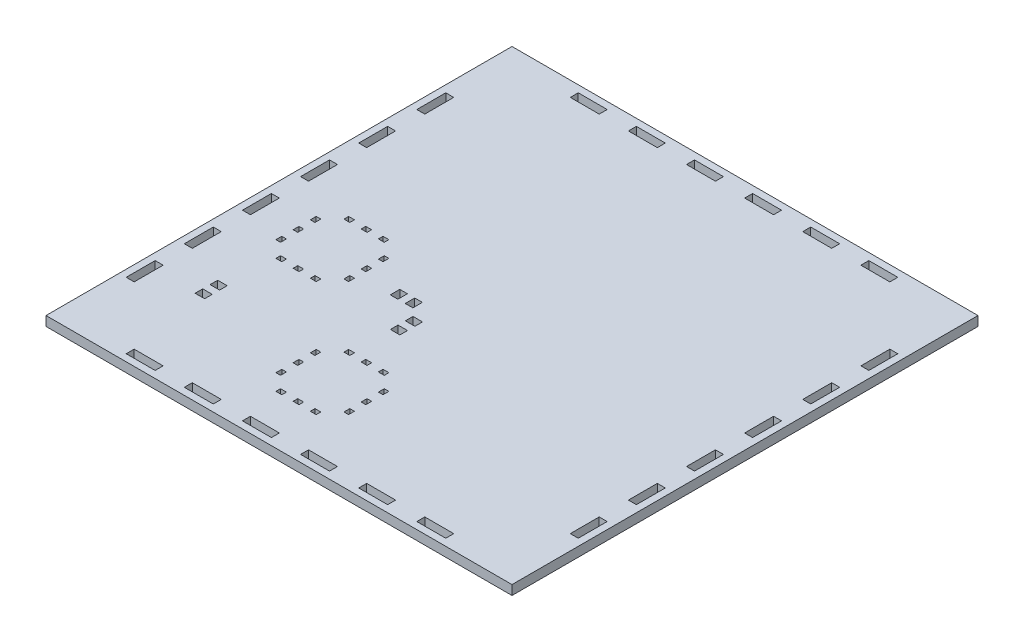
from build123d import *

# Parameters (mm, degrees)
SKETCH1_W           = 311.4
SKETCH1_H           = 311.4
SKETCH1_W_2         = 5.4
SKETCH1_H_2         = 19.425
SKETCH1_W_3         = 19.425
SKETCH1_H_3         = 5.4
SKETCH1_W_4         = 4.000000243
SKETCH1_H_4         = 3.174999693
SKETCH1_W_5         = 3.175000307
SKETCH1_H_5         = 3.999999757
SKETCH1_H_6         = 3.999999756
SKETCH1_W_6         = 4
SKETCH1_H_7         = 3.175
SKETCH1_W_7         = 3.175
SKETCH1_H_8         = 4
SKETCH1_W_8         = 3.174999693
SKETCH1_H_9         = 4.000000243
SKETCH1_H_10        = 4.000000244
BOSS_EXTRUDE4_DEPTH = 6.35
SKETCH4_W           = 19.425
SKETCH4_H           = 5.4
SKETCH4_W_2         = 5.4
SKETCH4_H_2         = 19.425
CUT_EXTRUDE3_DEPTH  = 6.35
SKETCH5_W           = 311.48128
SKETCH5_H           = 311.48128
SKETCH5_W_2         = 19.34372
SKETCH5_H_2         = 5.31872
SKETCH5_W_3         = 5.31872
SKETCH5_H_3         = 19.34372
SKETCH5_W_4         = 3.918720243
SKETCH5_H_4         = 3.093719693
SKETCH5_W_5         = 3.09372
SKETCH5_H_5         = 3.91872
SKETCH5_W_6         = 3.91872
SKETCH5_H_6         = 3.09372
SKETCH5_W_7         = 3.093720307
SKETCH5_H_7         = 3.918719757
SKETCH5_H_8         = 3.918719756
SKETCH5_W_8         = 3.093719693
SKETCH5_H_9         = 3.918720243
SKETCH5_H_10        = 3.918720244
BOSS_EXTRUDE5_DEPTH = 6.35
SKETCH7_W           = 6.35
SKETCH7_H           = 5.081279906
SKETCH7_W_2         = 5.081279906
SKETCH7_H_2         = 6.35
CUT_EXTRUDE4_DEPTH  = 6.35


with BuildPart() as part:
    # Sketch1 → Boss-Extrude4 (new body)
    with BuildSketch(Plane(origin=(0, 0, 0), x_dir=(1, 0, 0), z_dir=(0, 1, 0))):
        with Locations((148.1875, 148.2125)):
            Rectangle(SKETCH1_W, SKETCH1_H)
        with Locations((-0.2125, 51.075)):
            Rectangle(SKETCH1_W_2, SKETCH1_H_2, mode=Mode.SUBTRACT)
        with Locations((-0.2125, 89.925)):
            Rectangle(SKETCH1_W_2, SKETCH1_H_2, mode=Mode.SUBTRACT)
        with Locations((-0.2125, 128.775)):
            Rectangle(SKETCH1_W_2, SKETCH1_H_2, mode=Mode.SUBTRACT)
        with Locations((-0.2125, 167.625)):
            Rectangle(SKETCH1_W_2, SKETCH1_H_2, mode=Mode.SUBTRACT)
        with Locations((-0.2125, 206.475)):
            Rectangle(SKETCH1_W_2, SKETCH1_H_2, mode=Mode.SUBTRACT)
        with Locations((-0.2125, 245.325)):
            Rectangle(SKETCH1_W_2, SKETCH1_H_2, mode=Mode.SUBTRACT)
        with Locations((51.075, 296.6125)):
            Rectangle(SKETCH1_W_3, SKETCH1_H_3, mode=Mode.SUBTRACT)
        with Locations((89.925, 296.6125)):
            Rectangle(SKETCH1_W_3, SKETCH1_H_3, mode=Mode.SUBTRACT)
        with Locations((128.775, 296.6125)):
            Rectangle(SKETCH1_W_3, SKETCH1_H_3, mode=Mode.SUBTRACT)
        with Locations((167.625, 296.6125)):
            Rectangle(SKETCH1_W_3, SKETCH1_H_3, mode=Mode.SUBTRACT)
        with Locations((206.475, 296.6125)):
            Rectangle(SKETCH1_W_3, SKETCH1_H_3, mode=Mode.SUBTRACT)
        with Locations((245.325, 296.6125)):
            Rectangle(SKETCH1_W_3, SKETCH1_H_3, mode=Mode.SUBTRACT)
        with Locations((296.5875, 245.35)):
            Rectangle(SKETCH1_W_2, SKETCH1_H_2, mode=Mode.SUBTRACT)
        with Locations((296.5875, 206.5)):
            Rectangle(SKETCH1_W_2, SKETCH1_H_2, mode=Mode.SUBTRACT)
        with Locations((296.5875, 167.65)):
            Rectangle(SKETCH1_W_2, SKETCH1_H_2, mode=Mode.SUBTRACT)
        with Locations((296.5875, 128.8)):
            Rectangle(SKETCH1_W_2, SKETCH1_H_2, mode=Mode.SUBTRACT)
        with Locations((296.5875, 89.95)):
            Rectangle(SKETCH1_W_2, SKETCH1_H_2, mode=Mode.SUBTRACT)
        with Locations((296.5875, 51.1)):
            Rectangle(SKETCH1_W_2, SKETCH1_H_2, mode=Mode.SUBTRACT)
        with Locations((245.3, -0.1875)):
            Rectangle(SKETCH1_W_3, SKETCH1_H_3, mode=Mode.SUBTRACT)
        with Locations((206.45, -0.1875)):
            Rectangle(SKETCH1_W_3, SKETCH1_H_3, mode=Mode.SUBTRACT)
        with Locations((167.6, -0.1875)):
            Rectangle(SKETCH1_W_3, SKETCH1_H_3, mode=Mode.SUBTRACT)
        with Locations((128.75, -0.1875)):
            Rectangle(SKETCH1_W_3, SKETCH1_H_3, mode=Mode.SUBTRACT)
        with Locations((89.9, -0.1875)):
            Rectangle(SKETCH1_W_3, SKETCH1_H_3, mode=Mode.SUBTRACT)
        with Locations((51.05, -0.1875)):
            Rectangle(SKETCH1_W_3, SKETCH1_H_3, mode=Mode.SUBTRACT)
        with Locations((38.162499879, 149.42500074)):
            Rectangle(SKETCH1_W_4, SKETCH1_H_4, mode=Mode.SUBTRACT)
        with Locations((49.662499879, 149.42500074)):
            Rectangle(SKETCH1_W_4, SKETCH1_H_4, mode=Mode.SUBTRACT)
        with Locations((61.162499879, 149.42500074)):
            Rectangle(SKETCH1_W_4, SKETCH1_H_4, mode=Mode.SUBTRACT)
        with Locations((72.40000236, 138.187501742)):
            Rectangle(SKETCH1_W_5, SKETCH1_H_5, mode=Mode.SUBTRACT)
        with Locations((72.40000236, 126.68750181)):
            Rectangle(SKETCH1_W_5, SKETCH1_H_5, mode=Mode.SUBTRACT)
        with Locations((72.40000236, 115.187501877)):
            Rectangle(SKETCH1_W_5, SKETCH1_H_6, mode=Mode.SUBTRACT)
        with Locations((61.162501621, 103.95)):
            Rectangle(SKETCH1_W_6, SKETCH1_H_7, mode=Mode.SUBTRACT)
        with Locations((49.662501621, 103.95)):
            Rectangle(SKETCH1_W_6, SKETCH1_H_7, mode=Mode.SUBTRACT)
        with Locations((38.162501621, 103.95)):
            Rectangle(SKETCH1_W_6, SKETCH1_H_7, mode=Mode.SUBTRACT)
        with Locations((26.925001621, 115.1875)):
            Rectangle(SKETCH1_W_7, SKETCH1_H_8, mode=Mode.SUBTRACT)
        with Locations((26.925001621, 126.6875)):
            Rectangle(SKETCH1_W_7, SKETCH1_H_8, mode=Mode.SUBTRACT)
        with Locations((26.925001621, 138.1875)):
            Rectangle(SKETCH1_W_7, SKETCH1_H_8, mode=Mode.SUBTRACT)
        with Locations((115.162499879, 72.42500074)):
            Rectangle(SKETCH1_W_4, SKETCH1_H_4, mode=Mode.SUBTRACT)
        with Locations((126.662499879, 72.42500074)):
            Rectangle(SKETCH1_W_4, SKETCH1_H_4, mode=Mode.SUBTRACT)
        with Locations((138.162499879, 72.42500074)):
            Rectangle(SKETCH1_W_4, SKETCH1_H_4, mode=Mode.SUBTRACT)
        with Locations((149.400002361, 61.187501743)):
            Rectangle(SKETCH1_W_8, SKETCH1_H_9, mode=Mode.SUBTRACT)
        with Locations((149.400002361, 49.68750181)):
            Rectangle(SKETCH1_W_8, SKETCH1_H_9, mode=Mode.SUBTRACT)
        with Locations((149.400002361, 38.187501877)):
            Rectangle(SKETCH1_W_8, SKETCH1_H_10, mode=Mode.SUBTRACT)
        with Locations((138.162501621, 26.95)):
            Rectangle(SKETCH1_W_6, SKETCH1_H_7, mode=Mode.SUBTRACT)
        with Locations((126.662501621, 26.95)):
            Rectangle(SKETCH1_W_6, SKETCH1_H_7, mode=Mode.SUBTRACT)
        with Locations((115.162501621, 26.95)):
            Rectangle(SKETCH1_W_6, SKETCH1_H_7, mode=Mode.SUBTRACT)
        with Locations((103.925001621, 38.1875)):
            Rectangle(SKETCH1_W_7, SKETCH1_H_8, mode=Mode.SUBTRACT)
        with Locations((103.925001621, 49.6875)):
            Rectangle(SKETCH1_W_7, SKETCH1_H_8, mode=Mode.SUBTRACT)
        with Locations((103.925001621, 61.1875)):
            Rectangle(SKETCH1_W_7, SKETCH1_H_8, mode=Mode.SUBTRACT)
    extrude(amount=BOSS_EXTRUDE4_DEPTH)

    # Sketch4 → Cut-Extrude3 (cut)
    with BuildSketch(Plane(origin=(0, 6.35, 0), x_dir=(1, 0, 0), z_dir=(0, 1, 0))):
        with Locations((12.225, 296.6125)):
            Rectangle(SKETCH4_W, SKETCH4_H)
        with Locations((-0.2125, 284.175)):
            Rectangle(SKETCH4_W_2, SKETCH4_H_2)
        with BuildLine():
            ThreePointArc((2.512500017, 299.287442129), (-1.322027524, 297.714705253), (-2.9125, 293.8875))
            Line((-2.9125, 293.8875), (2.4875, 293.8875))
            Line((2.4875, 293.8875), (2.5125, 293.9125))
            Line((2.5125, 293.9125), (2.5125, 299.287442129))
        make_face()
        with BuildLine():
            Line((293.8875, 293.9125), (299.2875, 293.9125))
            ThreePointArc((299.2875, 293.9125), (297.705876618, 297.730876618), (293.8875, 299.3125))
            Line((293.8875, 299.3125), (293.8875, 293.9125))
        make_face()
        with Locations((284.175, 296.6125)):
            Rectangle(SKETCH4_W, SKETCH4_H)
        with Locations((296.5875, 284.2)):
            Rectangle(SKETCH4_W_2, SKETCH4_H_2)
        with Locations((-0.2125, 12.225)):
            Rectangle(SKETCH4_W_2, SKETCH4_H_2)
        with Locations((12.2, -0.1875)):
            Rectangle(SKETCH4_W, SKETCH4_H)
        with BuildLine():
            ThreePointArc((2.4875, -2.8875), (-1.330876618, -1.305876618), (-2.9125, 2.5125))
            Line((-2.9125, 2.5125), (2.4875, 2.5125))
            Line((2.4875, 2.5125), (2.4875, -2.8875))
        make_face()
        with BuildLine():
            Line((293.8875, 2.5375), (293.8625, 2.5125))
            Line((293.8625, 2.5125), (293.8625, -2.8875))
            ThreePointArc((293.8625, -2.8875), (297.689705247, -1.29702753), (299.262442129, 2.5375))
            Line((299.262442129, 2.5375), (293.8875, 2.5375))
        make_face()
        with Locations((284.15, -0.1875)):
            Rectangle(SKETCH4_W, SKETCH4_H)
        with Locations((296.5875, 12.25)):
            Rectangle(SKETCH4_W_2, SKETCH4_H_2)
    extrude(amount=-CUT_EXTRUDE3_DEPTH, mode=Mode.SUBTRACT)

    # Sketch5 → Boss-Extrude5 (add)
    with BuildSketch(Plane(origin=(0, 6.35, 0), x_dir=(1, 0, 0), z_dir=(0, 1, 0))):
        with Locations((148.1875, 148.2125)):
            Rectangle(SKETCH5_W, SKETCH5_H)
        with Locations((245.325, 296.6125)):
            Rectangle(SKETCH5_W_2, SKETCH5_H_2, mode=Mode.SUBTRACT)
        with Locations((296.5875, 206.5)):
            Rectangle(SKETCH5_W_3, SKETCH5_H_3, mode=Mode.SUBTRACT)
        with Locations((296.5875, 51.1)):
            Rectangle(SKETCH5_W_3, SKETCH5_H_3, mode=Mode.SUBTRACT)
        with Locations((296.5875, 245.35)):
            Rectangle(SKETCH5_W_3, SKETCH5_H_3, mode=Mode.SUBTRACT)
        with Locations((296.5875, 167.65)):
            Rectangle(SKETCH5_W_3, SKETCH5_H_3, mode=Mode.SUBTRACT)
        with Locations((51.075, 296.6125)):
            Rectangle(SKETCH5_W_2, SKETCH5_H_2, mode=Mode.SUBTRACT)
        with Locations((296.5875, 128.8)):
            Rectangle(SKETCH5_W_3, SKETCH5_H_3, mode=Mode.SUBTRACT)
        with Locations((245.3, -0.1875)):
            Rectangle(SKETCH5_W_2, SKETCH5_H_2, mode=Mode.SUBTRACT)
        with Locations((206.45, -0.1875)):
            Rectangle(SKETCH5_W_2, SKETCH5_H_2, mode=Mode.SUBTRACT)
        with Locations((89.925, 296.6125)):
            Rectangle(SKETCH5_W_2, SKETCH5_H_2, mode=Mode.SUBTRACT)
        with Locations((296.5875, 89.95)):
            Rectangle(SKETCH5_W_3, SKETCH5_H_3, mode=Mode.SUBTRACT)
        with Locations((128.775, 296.6125)):
            Rectangle(SKETCH5_W_2, SKETCH5_H_2, mode=Mode.SUBTRACT)
        with Locations((-0.2125, 167.625)):
            Rectangle(SKETCH5_W_3, SKETCH5_H_3, mode=Mode.SUBTRACT)
        with Locations((167.625, 296.6125)):
            Rectangle(SKETCH5_W_2, SKETCH5_H_2, mode=Mode.SUBTRACT)
        with Locations((167.6, -0.1875)):
            Rectangle(SKETCH5_W_2, SKETCH5_H_2, mode=Mode.SUBTRACT)
        with Locations((206.475, 296.6125)):
            Rectangle(SKETCH5_W_2, SKETCH5_H_2, mode=Mode.SUBTRACT)
        with Locations((-0.2125, 245.325)):
            Rectangle(SKETCH5_W_3, SKETCH5_H_3, mode=Mode.SUBTRACT)
        with Locations((128.75, -0.1875)):
            Rectangle(SKETCH5_W_2, SKETCH5_H_2, mode=Mode.SUBTRACT)
        with Locations((-0.2125, 206.475)):
            Rectangle(SKETCH5_W_3, SKETCH5_H_3, mode=Mode.SUBTRACT)
        with Locations((49.662499879, 149.42500074)):
            Rectangle(SKETCH5_W_4, SKETCH5_H_4, mode=Mode.SUBTRACT)
        with Locations((89.9, -0.1875)):
            Rectangle(SKETCH5_W_2, SKETCH5_H_2, mode=Mode.SUBTRACT)
        with Locations((61.162499879, 149.42500074)):
            Rectangle(SKETCH5_W_4, SKETCH5_H_4, mode=Mode.SUBTRACT)
        with Locations((51.05, -0.1875)):
            Rectangle(SKETCH5_W_2, SKETCH5_H_2, mode=Mode.SUBTRACT)
        with Locations((38.162499879, 149.42500074)):
            Rectangle(SKETCH5_W_4, SKETCH5_H_4, mode=Mode.SUBTRACT)
        with Locations((-0.2125, 51.075)):
            Rectangle(SKETCH5_W_3, SKETCH5_H_3, mode=Mode.SUBTRACT)
        with Locations((-0.2125, 89.925)):
            Rectangle(SKETCH5_W_3, SKETCH5_H_3, mode=Mode.SUBTRACT)
        with Locations((26.925001621, 138.1875)):
            Rectangle(SKETCH5_W_5, SKETCH5_H_5, mode=Mode.SUBTRACT)
        with Locations((-0.2125, 128.775)):
            Rectangle(SKETCH5_W_3, SKETCH5_H_3, mode=Mode.SUBTRACT)
        with Locations((26.925001621, 126.6875)):
            Rectangle(SKETCH5_W_5, SKETCH5_H_5, mode=Mode.SUBTRACT)
        with Locations((26.925001621, 115.1875)):
            Rectangle(SKETCH5_W_5, SKETCH5_H_5, mode=Mode.SUBTRACT)
        with Locations((38.162501621, 103.95)):
            Rectangle(SKETCH5_W_6, SKETCH5_H_6, mode=Mode.SUBTRACT)
        with Locations((49.662501621, 103.95)):
            Rectangle(SKETCH5_W_6, SKETCH5_H_6, mode=Mode.SUBTRACT)
        with Locations((61.162501621, 103.95)):
            Rectangle(SKETCH5_W_6, SKETCH5_H_6, mode=Mode.SUBTRACT)
        with Locations((72.40000236, 138.187501742)):
            Rectangle(SKETCH5_W_7, SKETCH5_H_7, mode=Mode.SUBTRACT)
        with Locations((72.40000236, 126.68750181)):
            Rectangle(SKETCH5_W_7, SKETCH5_H_7, mode=Mode.SUBTRACT)
        with Locations((72.40000236, 115.187501877)):
            Rectangle(SKETCH5_W_7, SKETCH5_H_8, mode=Mode.SUBTRACT)
        with Locations((126.662499879, 72.42500074)):
            Rectangle(SKETCH5_W_4, SKETCH5_H_4, mode=Mode.SUBTRACT)
        with Locations((115.162499879, 72.42500074)):
            Rectangle(SKETCH5_W_4, SKETCH5_H_4, mode=Mode.SUBTRACT)
        with Locations((138.162499879, 72.42500074)):
            Rectangle(SKETCH5_W_4, SKETCH5_H_4, mode=Mode.SUBTRACT)
        with Locations((149.400002361, 61.187501743)):
            Rectangle(SKETCH5_W_8, SKETCH5_H_9, mode=Mode.SUBTRACT)
        with Locations((149.400002361, 49.68750181)):
            Rectangle(SKETCH5_W_8, SKETCH5_H_9, mode=Mode.SUBTRACT)
        with Locations((149.400002361, 38.187501877)):
            Rectangle(SKETCH5_W_8, SKETCH5_H_10, mode=Mode.SUBTRACT)
        with Locations((138.162501621, 26.95)):
            Rectangle(SKETCH5_W_6, SKETCH5_H_6, mode=Mode.SUBTRACT)
        with Locations((126.662501621, 26.95)):
            Rectangle(SKETCH5_W_6, SKETCH5_H_6, mode=Mode.SUBTRACT)
        with Locations((115.162501621, 26.95)):
            Rectangle(SKETCH5_W_6, SKETCH5_H_6, mode=Mode.SUBTRACT)
        with Locations((103.925001621, 38.1875)):
            Rectangle(SKETCH5_W_5, SKETCH5_H_5, mode=Mode.SUBTRACT)
        with Locations((103.925001621, 49.6875)):
            Rectangle(SKETCH5_W_5, SKETCH5_H_5, mode=Mode.SUBTRACT)
        with Locations((103.925001621, 61.1875)):
            Rectangle(SKETCH5_W_5, SKETCH5_H_5, mode=Mode.SUBTRACT)
    extrude(amount=-BOSS_EXTRUDE5_DEPTH)

    # Sketch7 → Cut-Extrude4 (cut)
    with BuildSketch(Plane.XZ):
        with Locations((32.56878001, -57.739466447)):
            Rectangle(SKETCH7_W, SKETCH7_H)
        with Locations((32.56878001, -67.739466353)):
            Rectangle(SKETCH7_W, SKETCH7_H)
        with Locations((118.796859812, -102.046446074)):
            Rectangle(SKETCH7_W, SKETCH7_H)
        with Locations((118.796859812, -112.04644598)):
            Rectangle(SKETCH7_W, SKETCH7_H)
        with Locations((108.081219859, -122.680805933)):
            Rectangle(SKETCH7_W_2, SKETCH7_H_2)
        with Locations((98.081219953, -122.680805933)):
            Rectangle(SKETCH7_W_2, SKETCH7_H_2)
    extrude(amount=-CUT_EXTRUDE4_DEPTH, mode=Mode.SUBTRACT)


solid = part.part
